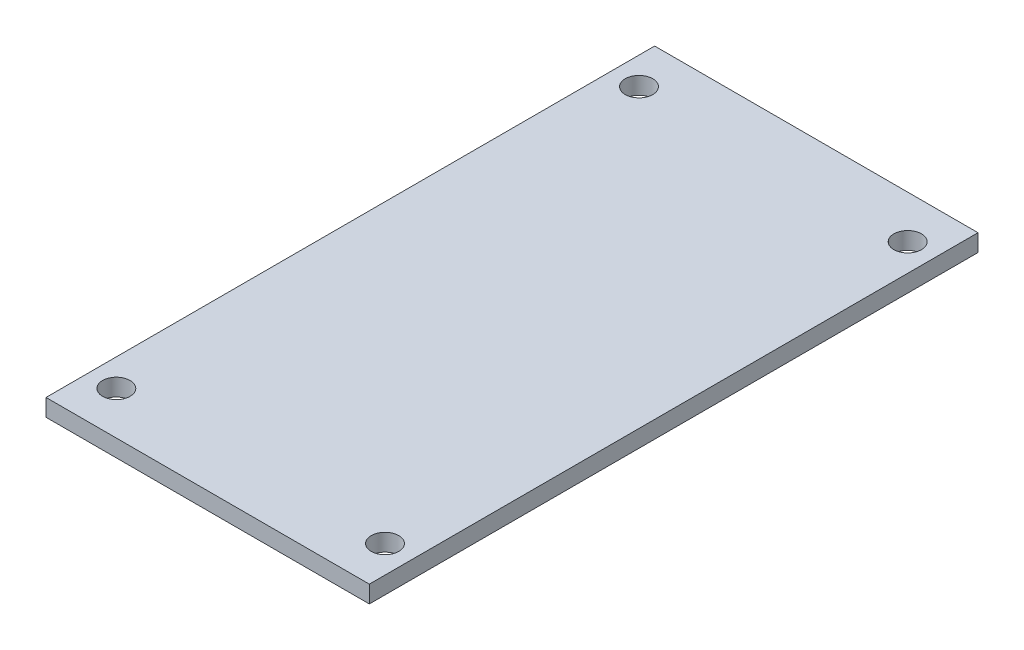
from build123d import *

# Parameters (mm, degrees)
SKETCH1_W           = 37.6
SKETCH1_H           = 70.78
SKETCH1_R           = 1.6
BOSS_EXTRUDE1_DEPTH = 2


with BuildPart() as part:
    # Sketch1 → Boss-Extrude1 (new body)
    with BuildSketch(Plane(origin=(0, 0, 0), x_dir=(1, 0, 0), z_dir=(0, 1, 0))):
        Rectangle(SKETCH1_W, SKETCH1_H)
        with Locations((15.62, 30.39)):
            Circle(SKETCH1_R, mode=Mode.SUBTRACT)
        with Locations((15.62, -30.39)):
            Circle(SKETCH1_R, mode=Mode.SUBTRACT)
        with Locations((-15.62, -30.39)):
            Circle(SKETCH1_R, mode=Mode.SUBTRACT)
        with Locations((-15.62, 30.39)):
            Circle(SKETCH1_R, mode=Mode.SUBTRACT)
    extrude(amount=BOSS_EXTRUDE1_DEPTH)


solid = part.part
